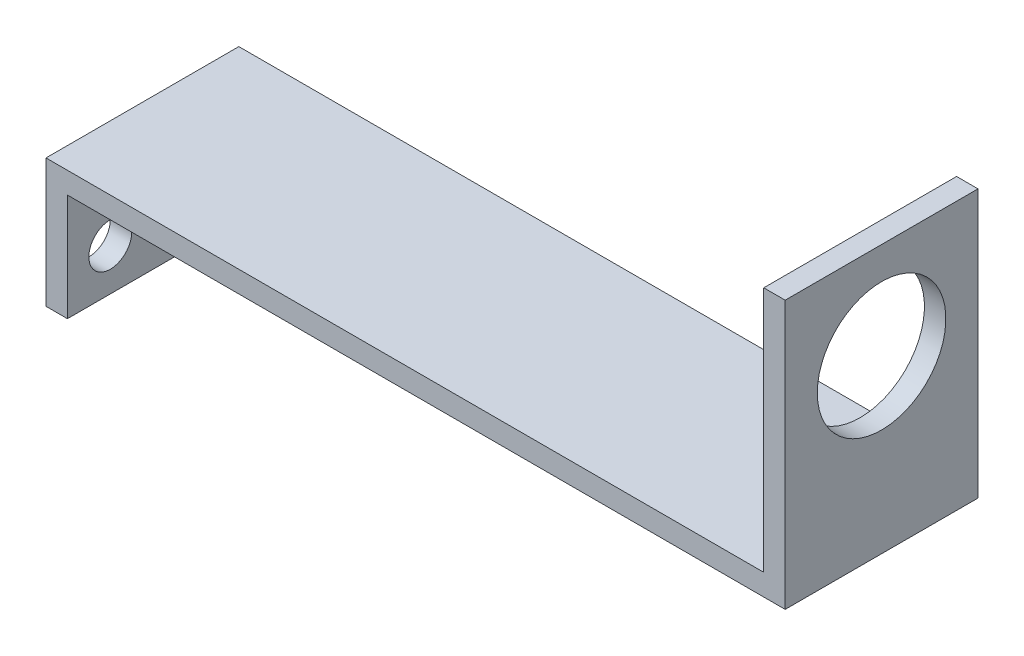
from build123d import *

# Parameters (mm, degrees)
BOSS_EXTRUDE1_DEPTH = 18
CUT_EXTRUDE1_REACH  = 71
SKETCH2_R           = 2
CUT_EXTRUDE2_REACH  = 4
SKETCH3_R           = 6


with BuildPart() as part:
    # Sketch1 → Boss-Extrude1 (new body)
    with BuildSketch(Plane.XY):
        Polygon((0, 0), (0, 12), (67, 12), (67, 35), (69, 35), (69, 10), (2, 10), (2, 0), align=None)
    extrude(amount=BOSS_EXTRUDE1_DEPTH)

    # Sketch2 → Cut-Extrude1 (cut, up to next)
    with BuildSketch(Plane.ZY, mode=Mode.PRIVATE) as cut_extrude1_sk1:
        with Locations((4, 4)):
            Circle(SKETCH2_R)
    cut_extrude1_tool1 = extrude(cut_extrude1_sk1.sketch, amount=-CUT_EXTRUDE1_REACH, mode=Mode.PRIVATE) & part.part
    add(cut_extrude1_tool1.solids().sort_by_distance((0, 4, 4))[0], mode=Mode.SUBTRACT)
    # Sketch2 → Cut-Extrude1 (cut, up to next)
    with BuildSketch(Plane.ZY, mode=Mode.PRIVATE) as cut_extrude1_sk2:
        with Locations((14, 4)):
            Circle(SKETCH2_R)
    cut_extrude1_tool2 = extrude(cut_extrude1_sk2.sketch, amount=-CUT_EXTRUDE1_REACH, mode=Mode.PRIVATE) & part.part
    add(cut_extrude1_tool2.solids().sort_by_distance((0, 4, 14))[0], mode=Mode.SUBTRACT)

    # Sketch3 → Cut-Extrude2 (cut, up to next)
    with BuildSketch(Plane.ZY.offset(-67), mode=Mode.PRIVATE) as cut_extrude2_sk1:
        with Locations((9, 26)):
            Circle(SKETCH3_R)
    cut_extrude2_tool1 = extrude(cut_extrude2_sk1.sketch, amount=-CUT_EXTRUDE2_REACH, mode=Mode.PRIVATE) & part.part
    add(cut_extrude2_tool1.solids().sort_by_distance((67, 26, 9))[0], mode=Mode.SUBTRACT)


solid = part.part
